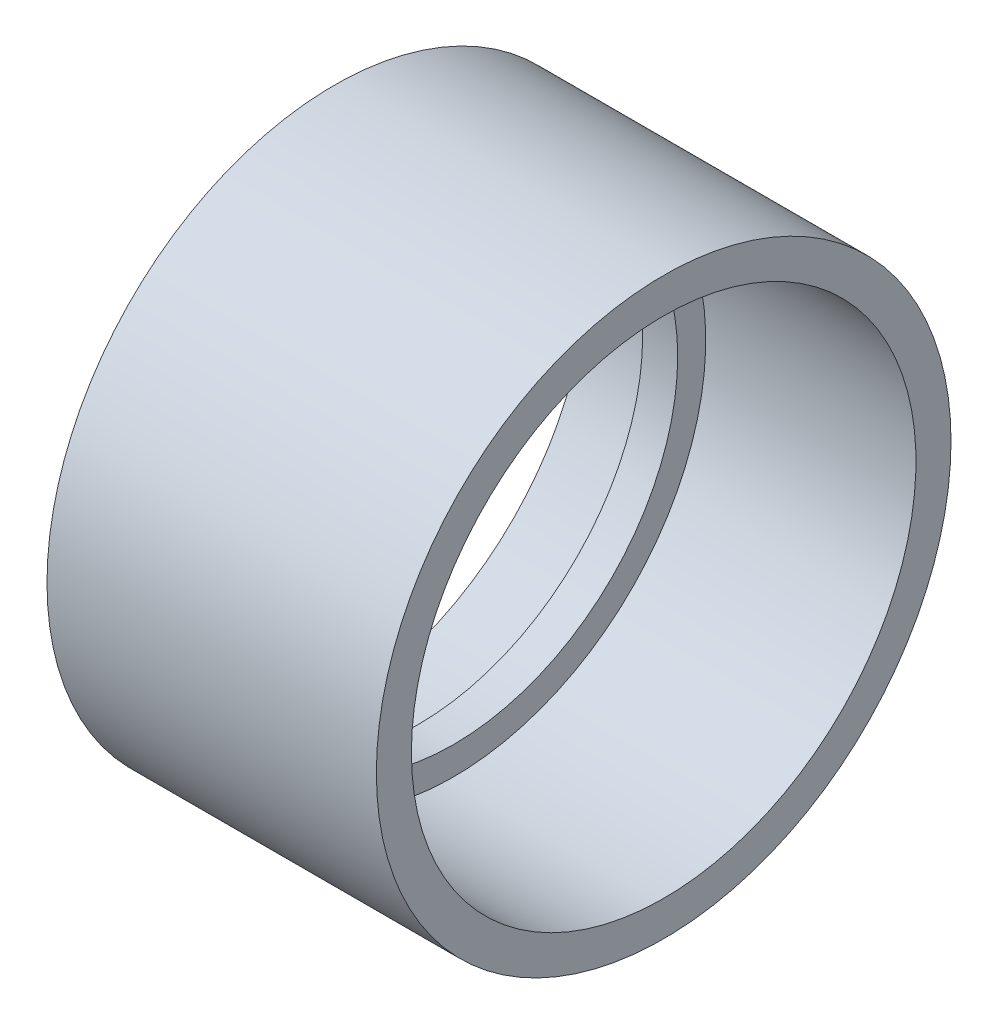
from build123d import *


with BuildPart() as part:
    # Эскиз1 → Повернуть1 (revolve)
    with BuildSketch(Plane.XY):
        Polygon((-5, 32), (0, 32), (0, 36), (30, 36), (30, 41), (-17, 41), (-17, 36), (-5, 36), align=None)
    revolve(axis=Axis((-1000, 0, 0), (1, 0, 0)))


solid = part.part
